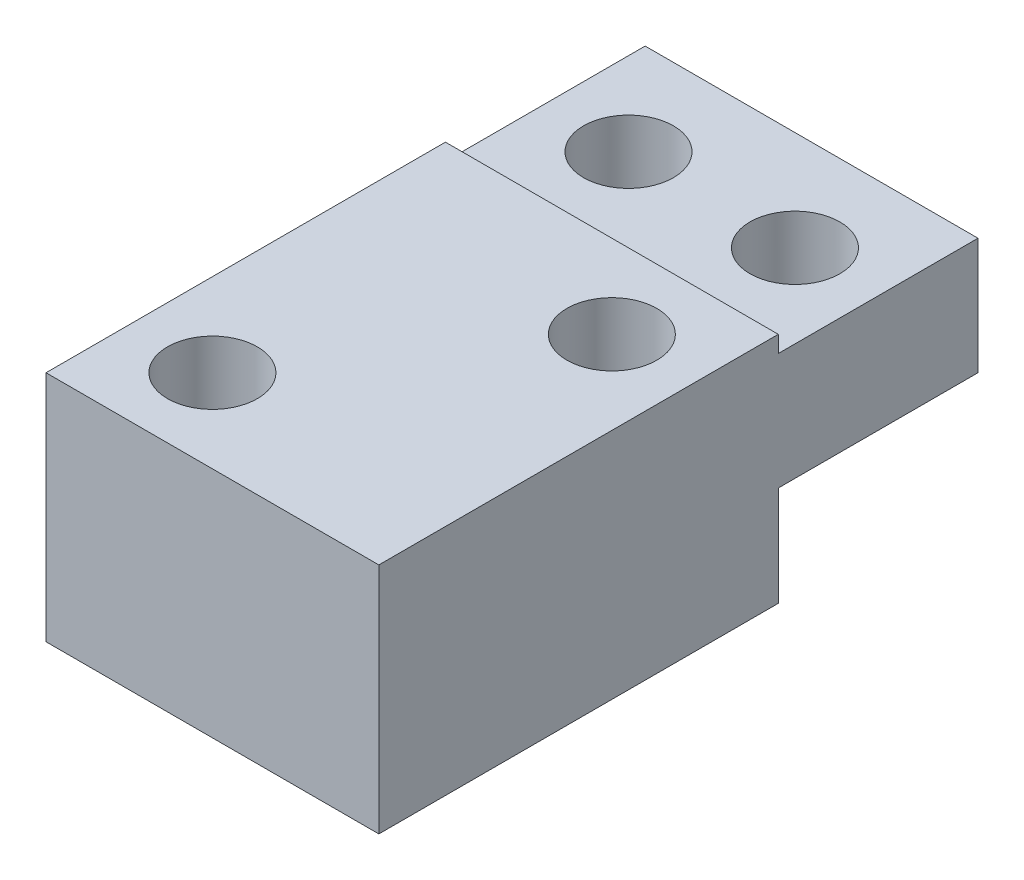
from build123d import *

# Parameters (mm, degrees)
SKETCH1_W              = 10
SKETCH1_H              = 18
BOSS_EXTRUDE1_DEPTH    = 7
SKETCH2_W              = 10
SKETCH2_H              = 6
CUT_EXTRUDE1_DEPTH     = 0.5
M2_5_CLEARANCE_HOLE1_D = 2.7
SKETCH5_W              = 10
SKETCH5_H              = 6
CUT_EXTRUDE2_DEPTH     = 3
M2_5_CLEARANCE_HOLE2_D = 2.7


with BuildPart() as part:
    # Sketch1 → Boss-Extrude1 (new body)
    with BuildSketch(Plane(origin=(0, 0, 0), x_dir=(1, 0, 0), z_dir=(0, 1, 0))):
        Rectangle(SKETCH1_W, SKETCH1_H)
    extrude(amount=BOSS_EXTRUDE1_DEPTH)

    # Sketch2 → Cut-Extrude1 (cut)
    with BuildSketch(Plane(origin=(0, 7, 0), x_dir=(1, 0, 0), z_dir=(0, 1, 0))):
        with Locations((0, 6)):
            Rectangle(SKETCH2_W, SKETCH2_H)
    extrude(amount=-CUT_EXTRUDE1_DEPTH, mode=Mode.SUBTRACT)

    # M2.5 Clearance Hole1 (through all)
    with Locations(Plane(origin=(0, 7, 0), x_dir=(1, 0, 0), z_dir=(0, 1, 0))):
        with Locations((-2.5, -6.5), (2.5, 0.5)):
            Hole(M2_5_CLEARANCE_HOLE1_D / 2)

    # Sketch5 → Cut-Extrude2 (cut)
    with BuildSketch(Plane.XZ):
        with Locations((0, -6)):
            Rectangle(SKETCH5_W, SKETCH5_H)
    extrude(amount=-CUT_EXTRUDE2_DEPTH, mode=Mode.SUBTRACT)

    # M2.5 Clearance Hole2 (through all)
    with Locations(Plane(origin=(0, 3, 0), x_dir=(-1, 0, 0), z_dir=(0, -1, 0))):
        with Locations((-2.5, 6), (2.5, 6)):
            Hole(M2_5_CLEARANCE_HOLE2_D / 2)


solid = part.part
